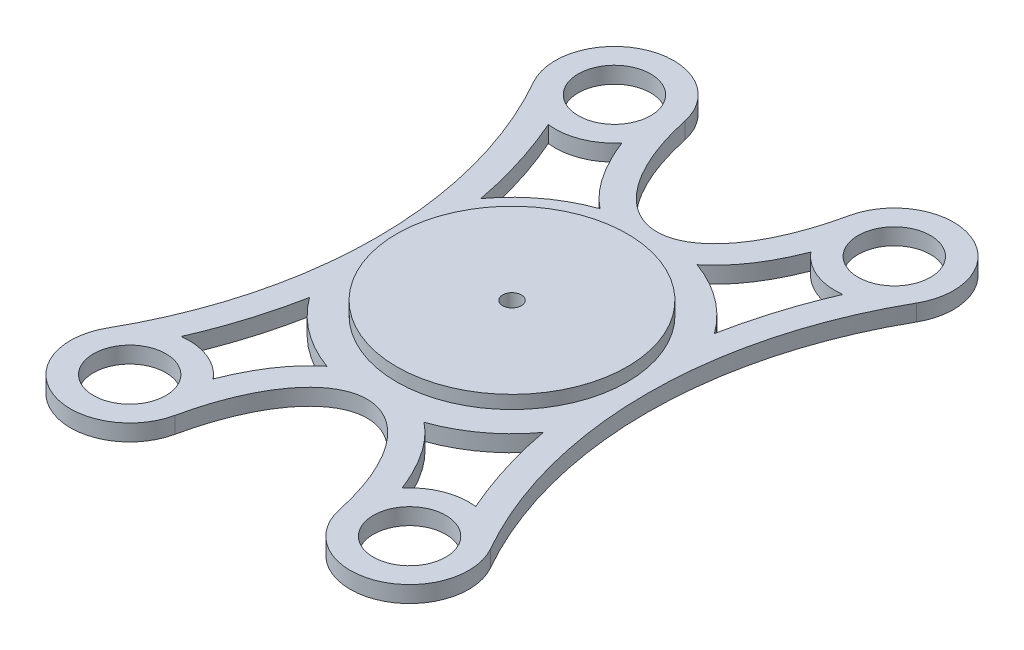
from build123d import *

# Parameters (mm, degrees)
SKETCH1_W                 = 100
SKETCH1_H                 = 100
BOSS_EXTRUDE1_DEPTH       = 2.5
SKETCH2_W                 = 100
SKETCH2_H                 = 100
SKETCH2_R                 = 5.5
CUT_EXTRUDE1_DEPTH        = 10
CUT_EXTRUDE3_DEPTH        = 10
SKETCH6_R                 = 17.5
BOSS_EXTRUDE11_DEPTH      = 2
BOSS_EXTRUDE11_DEPTH_BACK = 5
SKETCH7_R                 = 1.425
CUT_EXTRUDE4_DEPTH        = 56.337685614


with BuildPart() as part:
    # Sketch1 → Boss-Extrude1 (new body)
    with BuildSketch(Plane(origin=(0, 0, 0), x_dir=(1, 0, 0), z_dir=(0, 1, 0))):
        Rectangle(SKETCH1_W, SKETCH1_H)
    extrude(amount=BOSS_EXTRUDE1_DEPTH)

    # Sketch2 → Cut-Extrude1 (cut)
    with BuildSketch(Plane(origin=(0, 2.5, 0), x_dir=(1, 0, 0), z_dir=(0, 1, 0))):
        Rectangle(SKETCH2_W, SKETCH2_H)
        with BuildLine():
            ThreePointArc((-29.074945731, -32.359707621), (-20.523161881, 0), (-29.074945731, 32.359707621))
            ThreePointArc((-29.074945731, 32.359707621), (-24.454355603, 45.216317777), (-12.450207096, 38.693841525))
            add(Edge.make_bspline(
                [(-12.450207096, 38.693841525), (0, -19.342739332), (12.450207096, 38.693841525)],
                knots=[5.128046308, 5.128046308, 5.128046308, 7.438324307, 7.438324307, 7.438324307], degree=2, weights=[1, 0.403791374, 1]))
            ThreePointArc((12.450207096, 38.693841525), (24.454355603, 45.216317777), (29.074945731, 32.359707621))
            ThreePointArc((29.074945731, 32.359707621), (20.523161881, 0), (29.074945731, -32.359707621))
            ThreePointArc((29.074945731, -32.359707621), (24.454355603, -45.216317777), (12.450207096, -38.693841525))
            add(Edge.make_bspline(
                [(12.450207096, -38.693841525), (0, 19.342739332), (-12.450207096, -38.693841525)],
                knots=[5.128046308, 5.128046308, 5.128046308, 7.438324307, 7.438324307, 7.438324307], degree=2, weights=[1, 0.403791374, 1]))
            ThreePointArc((-12.450207096, -38.693841525), (-24.454355603, -45.216317777), (-29.074945731, -32.359707621))
        make_face(mode=Mode.SUBTRACT)
        with Locations(Location((-21.25, 36.806079661, 0), (0, 0, 270))):
            Circle(SKETCH2_R)
        with Locations(Location((-21.25, -36.806079661, 0), (0, 0, 270))):
            Circle(SKETCH2_R)
        with Locations(Location((21.25, -36.806079661, 0), (0, 0, 270))):
            Circle(SKETCH2_R)
        with Locations(Location((21.25, 36.806079661, 0), (0, 0, 270))):
            Circle(SKETCH2_R)
    extrude(amount=-CUT_EXTRUDE1_DEPTH, mode=Mode.SUBTRACT)

    # Sketch4 → Cut-Extrude3 (cut)
    with BuildSketch(Plane(origin=(0, 2.5, 0), x_dir=(1, 0, 0), z_dir=(0, 1, 0))):
        with BuildLine():
            ThreePointArc((-17.749489284, -12.998293356), (-13.140045691, -17.64480658), (-7.367625104, -20.729643034))
            add(Edge.make_bspline(
                [(-7.367625104, -20.729643034), (-7.747241798, -21.030061446), (-8.114529726, -21.350348356), (-9.247106431, -22.428016295), (-9.96747496, -23.25295704), (-11.975526868, -25.945450431), (-13.113170007, -28.031524091), (-14.161311212, -30.568863064), (-14.254109179, -30.800153833), (-14.345065296, -31.033569225)],
                knots=[0.658936879, 0.658936879, 0.658936879, 0.658936879, 0.6875, 0.6875, 0.75, 0.75, 0.875, 0.875, 0.887405876, 0.887405876, 0.887405876, 0.887405876], degree=3))
            ThreePointArc((-14.345065296, -31.033569225), (-17.949067849, -28.433275654), (-22.357942029, -27.874536431))
            add(Edge.make_bspline(
                [(-17.749489284, -12.998293356), (-18.730013182, -18.148505445), (-20.279042278, -23.126345909), (-22.357942029, -27.874536431)],
                knots=[0.6784999, 0.6784999, 0.6784999, 0.6784999, 0.896036051, 0.896036051, 0.896036051, 0.896036051], degree=3, weights=[0.94303917, 0.94979881, 0.960677405, 0.975674954]))
        make_face()
        with BuildLine():
            ThreePointArc((7.367625104, -20.729643034), (13.140045691, -17.64480658), (17.749489284, -12.998293356))
            add(Edge.make_bspline(
                [(22.357942029, -27.874536431), (20.279042278, -23.126345909), (18.730013182, -18.148505445), (17.749489284, -12.998293356)],
                knots=[0.103963949, 0.103963949, 0.103963949, 0.103963949, 0.3215001, 0.3215001, 0.3215001, 0.3215001], degree=3, weights=[0.975674954, 0.960677405, 0.94979881, 0.94303917]))
            ThreePointArc((22.357942029, -27.874536431), (17.949067849, -28.433275654), (14.345065296, -31.033569225))
            add(Edge.make_bspline(
                [(14.345065296, -31.033569225), (14.254109179, -30.800153832), (14.161311212, -30.568863064), (13.113170007, -28.031524091), (11.975526868, -25.945450431), (9.96747496, -23.25295704), (9.247106431, -22.428016295), (8.114529726, -21.350348356), (7.747241798, -21.030061447), (7.367625104, -20.729643034)],
                knots=[0.112594124, 0.112594124, 0.112594124, 0.112594124, 0.125, 0.125, 0.25, 0.25, 0.3125, 0.3125, 0.341063121, 0.341063121, 0.341063121, 0.341063121], degree=3))
        make_face()
        with BuildLine():
            ThreePointArc((14.345065296, 31.033569225), (17.949067849, 28.433275654), (22.357942029, 27.874536431))
            add(Edge.make_bspline(
                [(17.749489284, 12.998293356), (18.730013182, 18.148505445), (20.279042278, 23.126345909), (22.357942029, 27.874536431)],
                knots=[0.6784999, 0.6784999, 0.6784999, 0.6784999, 0.896036051, 0.896036051, 0.896036051, 0.896036051], degree=3, weights=[0.94303917, 0.94979881, 0.960677405, 0.975674954]))
            ThreePointArc((17.749489284, 12.998293356), (13.140045691, 17.64480658), (7.367625104, 20.729643034))
            add(Edge.make_bspline(
                [(7.367625104, 20.729643034), (7.747241798, 21.030061446), (8.114529726, 21.350348356), (9.247106431, 22.428016295), (9.96747496, 23.25295704), (11.975526868, 25.945450431), (13.113170007, 28.031524091), (14.161311212, 30.568863064), (14.254109179, 30.800153833), (14.345065296, 31.033569225)],
                knots=[0.658936879, 0.658936879, 0.658936879, 0.658936879, 0.6875, 0.6875, 0.75, 0.75, 0.875, 0.875, 0.887405876, 0.887405876, 0.887405876, 0.887405876], degree=3))
        make_face()
        with BuildLine():
            ThreePointArc((-14.345065296, 31.033569225), (-17.949067849, 28.433275654), (-22.357942029, 27.874536431))
            add(Edge.make_bspline(
                [(-22.357942029, 27.874536431), (-20.279042278, 23.126345909), (-18.730013182, 18.148505445), (-17.749489284, 12.998293356)],
                knots=[0.103963949, 0.103963949, 0.103963949, 0.103963949, 0.3215001, 0.3215001, 0.3215001, 0.3215001], degree=3, weights=[0.975674954, 0.960677405, 0.94979881, 0.94303917]))
            ThreePointArc((-17.749489284, 12.998293356), (-13.140045691, 17.64480658), (-7.367625104, 20.729643034))
            add(Edge.make_bspline(
                [(-14.345065296, 31.033569225), (-14.254109179, 30.800153832), (-14.161311212, 30.568863064), (-13.113170007, 28.031524091), (-11.975526868, 25.945450431), (-9.96747496, 23.25295704), (-9.247106431, 22.428016295), (-8.114529726, 21.350348356), (-7.747241798, 21.030061447), (-7.367625104, 20.729643034)],
                knots=[0.112594124, 0.112594124, 0.112594124, 0.112594124, 0.125, 0.125, 0.25, 0.25, 0.3125, 0.3125, 0.341063121, 0.341063121, 0.341063121, 0.341063121], degree=3))
        make_face()
    extrude(amount=-CUT_EXTRUDE3_DEPTH, mode=Mode.SUBTRACT)

    # Sketch6 → Boss-Extrude11 (add, two sides)
    with BuildSketch(Plane(origin=(0, 2.5, 0), x_dir=(1, 0, 0), z_dir=(0, 1, 0))) as boss_extrude11_sk:
        with Locations(Location((0, 0, 0), (0, 0, 270))):
            Circle(SKETCH6_R)
    extrude(amount=BOSS_EXTRUDE11_DEPTH)
    extrude(boss_extrude11_sk.sketch, amount=-BOSS_EXTRUDE11_DEPTH_BACK)

    # Sketch7 → Cut-Extrude4 (cut, through all)
    with BuildSketch(Plane(origin=(0, 4.5, 0), x_dir=(1, 0, 0), z_dir=(0, 1, 0))):
        with Locations(Location((0, 0, 0), (0, 0, 270))):
            Circle(SKETCH7_R)
    extrude(amount=-CUT_EXTRUDE4_DEPTH, mode=Mode.SUBTRACT)


solid = part.part
